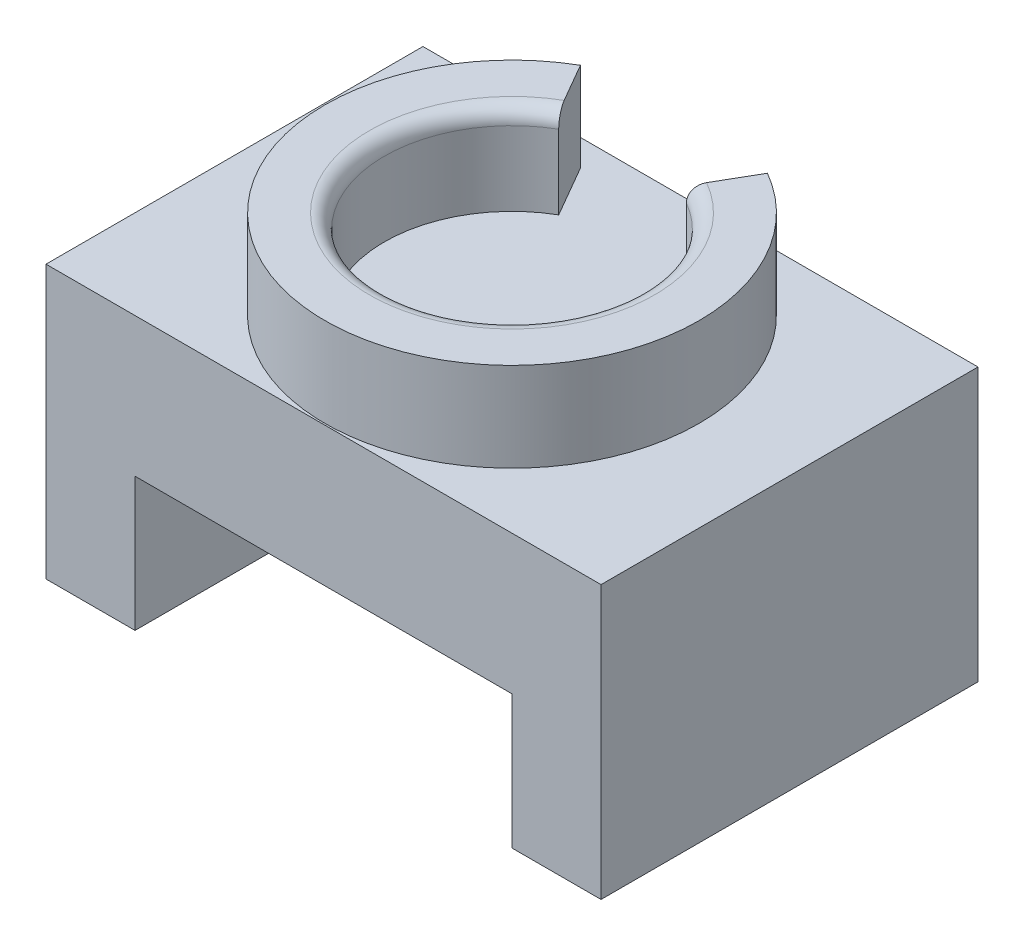
from build123d import *

# Parameters (mm, degrees)
BOSS_EXTRUDE1_DEPTH = 25.4
SKETCH2_R           = 12.6
SKETCH2_R_2         = 8.6
BOSS_EXTRUDE2_DEPTH = 6
CUT_EXTRUDE1_DEPTH  = 6
FILLET1_R           = 1


with BuildPart() as part:
    # Sketch1 → Boss-Extrude1 (new body)
    with BuildSketch(Plane.XY):
        Polygon((-10.189534884, 0), (-10.189534884, 9), (15.210465116, 9), (15.210465116, 0), (21.210465116, 0), (21.210465116, 18.375), (-16.189534884, 18.375), (-16.189534884, 0), align=None)
    extrude(amount=BOSS_EXTRUDE1_DEPTH)

    # Sketch2 → Boss-Extrude2 (add)
    with BuildSketch(Plane(origin=(0, 18.375, 0), x_dir=(1, 0, 0), z_dir=(0, 1, 0))):
        with Locations((2.510465116, -12.7)):
            Circle(SKETCH2_R)
        with Locations((2.510465116, -12.7)):
            Circle(SKETCH2_R_2, mode=Mode.SUBTRACT)
    extrude(amount=BOSS_EXTRUDE2_DEPTH)

    # Sketch3 → Cut-Extrude1 (cut)
    with BuildSketch(Plane(origin=(0, 24.375, 0), x_dir=(1, 0, 0), z_dir=(0, 1, 0))):
        with BuildLine():
            ThreePointArc((-1.789534884, -5.252181527), (0.284621328, -4.393037894), (2.510465116, -4.1))
            Line((2.510465116, -4.1), (2.510465116, -0.1))
            ThreePointArc((2.510465116, -0.1), (-0.750654852, -0.529334589), (-3.789534884, -1.788079912))
            Line((-3.789534884, -1.788079912), (-1.789534884, -5.252181527))
        make_face()
        with BuildLine():
            Line((2.510465116, -0.1), (2.510465116, -4.1))
            ThreePointArc((2.510465116, -4.1), (4.736308904, -4.393037894), (6.810465116, -5.252181527))
            Line((6.810465116, -5.252181527), (8.810465116, -1.788079912))
            ThreePointArc((8.810465116, -1.788079912), (5.771585085, -0.529334589), (2.510465116, -0.1))
        make_face()
    extrude(amount=-CUT_EXTRUDE1_DEPTH, mode=Mode.SUBTRACT)

    # Fillet1
    fillet1_edges = [part.edges().sort_by_distance(p)[0] for p in [
        (2.510465116, 24.375, 21.3),
    ]]
    fillet(fillet1_edges, radius=FILLET1_R)


solid = part.part
